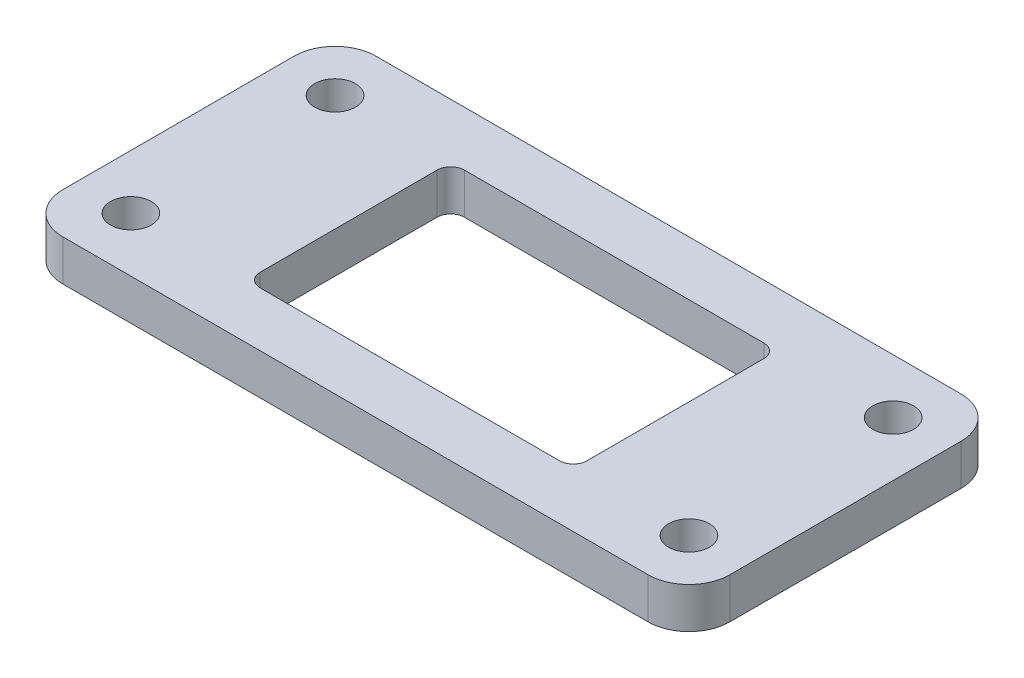
from build123d import *

# Parameters (mm, degrees)
SKETCH1_R           = 1.5
BOSS_EXTRUDE1_DEPTH = 3


with BuildPart() as part:
    # Sketch1 → Boss-Extrude1 (new body)
    with BuildSketch(Plane(origin=(0, 0, 0), x_dir=(1, 0, 0), z_dir=(0, 1, 0))):
        with BuildLine():
            Line((-4, 1), (-4, -16))
            ThreePointArc((-4, -16), (-3.121320344, -18.121320344), (-1, -19))
            Line((-1, -19), (42, -19))
            ThreePointArc((42, -19), (44.121320344, -18.121320344), (45, -16))
            Line((45, -16), (45, 1))
            ThreePointArc((45, 1), (44.121320344, 3.121320344), (42, 4))
            Line((42, 4), (-1, 4))
            ThreePointArc((-1, 4), (-3.121320344, 3.121320344), (-4, 1))
        make_face()
        Circle(SKETCH1_R, mode=Mode.SUBTRACT)
        with Locations((41, 0)):
            Circle(SKETCH1_R, mode=Mode.SUBTRACT)
        with Locations((41, -15)):
            Circle(SKETCH1_R, mode=Mode.SUBTRACT)
        with Locations((0, -15)):
            Circle(SKETCH1_R, mode=Mode.SUBTRACT)
        with BuildLine():
            Line((9.5, 0), (31.5, 0))
            ThreePointArc((31.5, 0), (32.207106781, -0.292893219), (32.5, -1))
            Line((32.5, -1), (32.5, -14))
            ThreePointArc((32.5, -14), (32.207106781, -14.707106781), (31.5, -15))
            Line((31.5, -15), (15.880823308, -15))
            Line((15.880823308, -15), (9.5, -15))
            ThreePointArc((9.5, -15), (8.792893219, -14.707106781), (8.5, -14))
            Line((8.5, -14), (8.5, -1))
            ThreePointArc((8.5, -1), (8.792893219, -0.292893219), (9.5, 0))
        make_face(mode=Mode.SUBTRACT)
    extrude(amount=BOSS_EXTRUDE1_DEPTH)


solid = part.part
